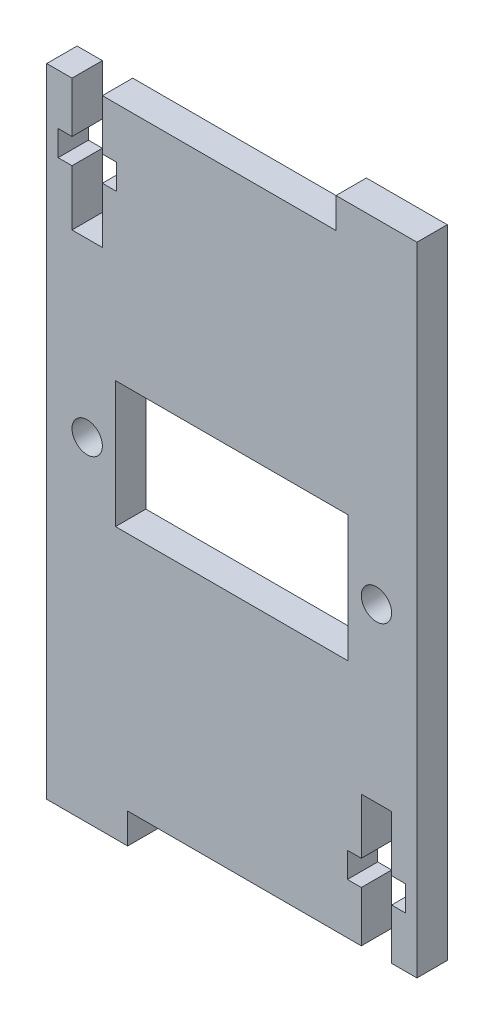
from build123d import *

# Parameters (mm, degrees)
ESBO_O1_R                = 1.5
ESBO_O1_W                = 23
ESBO_O1_H                = 12.5
RESSALTO_EXTRUS_O1_DEPTH = 3


with BuildPart() as part:
    # Esboço1 → Ressalto-extrusão1 (new body)
    with BuildSketch(Plane.XY):
        Polygon((11.242500706, -13), (11.242500706, -8), (12.617500706, -8), (12.617500706, -5.5), (11.242500706, -5.5), (11.242500706, 0), (8.242500706, 0), (8.242500706, -5.5), (6.867500706, -5.5), (6.867500706, -8), (8.242500706, -8), (8.242500706, -13), (-14.857499294, -13), (-14.857499294, -16), (-22.857499294, -16), (-22.857499294, -13), (-22.857499294, 25.3), (-22.857499294, 47), (-20.357499294, 47), (-20.357499294, 42), (-21.732499294, 42), (-21.732499294, 39.5), (-20.357499294, 39.5), (-20.357499294, 34), (-17.357499294, 34), (-17.357499294, 39.5), (-15.982499294, 39.5), (-15.982499294, 42), (-17.357499294, 42), (-17.357499294, 47), (5.742500706, 47), (5.742500706, 50), (13.742500706, 50), (13.742500706, -13), align=None)
        with Locations((-18.857499294, 17)):
            Circle(ESBO_O1_R, mode=Mode.SUBTRACT)
        with Locations((9.742500706, 17)):
            Circle(ESBO_O1_R, mode=Mode.SUBTRACT)
        with Locations((-4.557499294, 17)):
            Rectangle(ESBO_O1_W, ESBO_O1_H, mode=Mode.SUBTRACT)
    extrude(amount=RESSALTO_EXTRUS_O1_DEPTH)


solid = part.part
